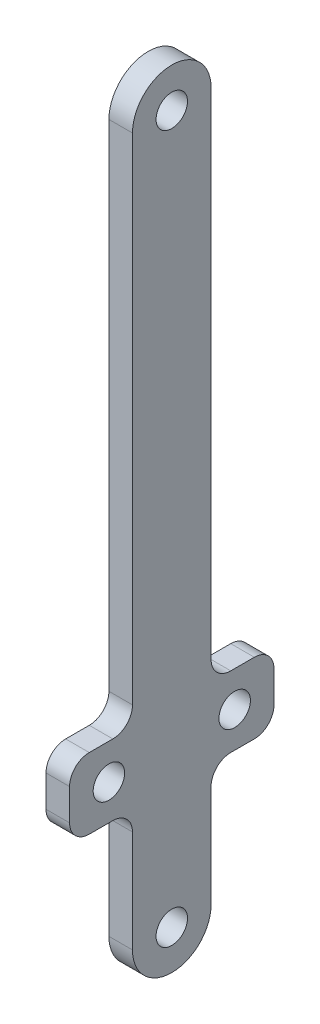
from build123d import *

# Parameters (mm, degrees)
SKETCH2_R           = 4
SKETCH2_W           = 52
SKETCH2_H           = 18
BOSS_EXTRUDE1_DEPTH = 6
FILLET1_R           = 5


with BuildPart() as part:
    # Sketch2 → Boss-Extrude1 (new body)
    with BuildSketch(Plane(origin=(0, 0, 0), x_dir=(0, 0, -1), z_dir=(1, 0, 0))):
        with BuildLine():
            Line((-10, 0), (-10, 180))
            ThreePointArc((-10, 180), (0, 190), (10, 180))
            Line((10, 180), (10, 0))
            ThreePointArc((10, 0), (0, -10), (-10, 0))
        make_face()
        Circle(SKETCH2_R, mode=Mode.SUBTRACT)
        with Locations((0, 180)):
            Circle(SKETCH2_R, mode=Mode.SUBTRACT)
        with Locations((0, 40)):
            Rectangle(SKETCH2_W, SKETCH2_H)
        with Locations((-16, 40)):
            Circle(SKETCH2_R, mode=Mode.SUBTRACT)
        with Locations((16, 40)):
            Circle(SKETCH2_R, mode=Mode.SUBTRACT)
    extrude(amount=BOSS_EXTRUDE1_DEPTH)

    # Fillet1
    fillet1_edges = [part.edges().sort_by_distance(p)[0] for p in [
        (3, 49, 10),
        (3, 49, -10),
        (3, 49, -26),
        (3, 31, -26),
        (3, 31, -10),
        (3, 31, 10),
        (3, 31, 26),
        (3, 49, 26),
    ]]
    fillet(fillet1_edges, radius=FILLET1_R)


solid = part.part
